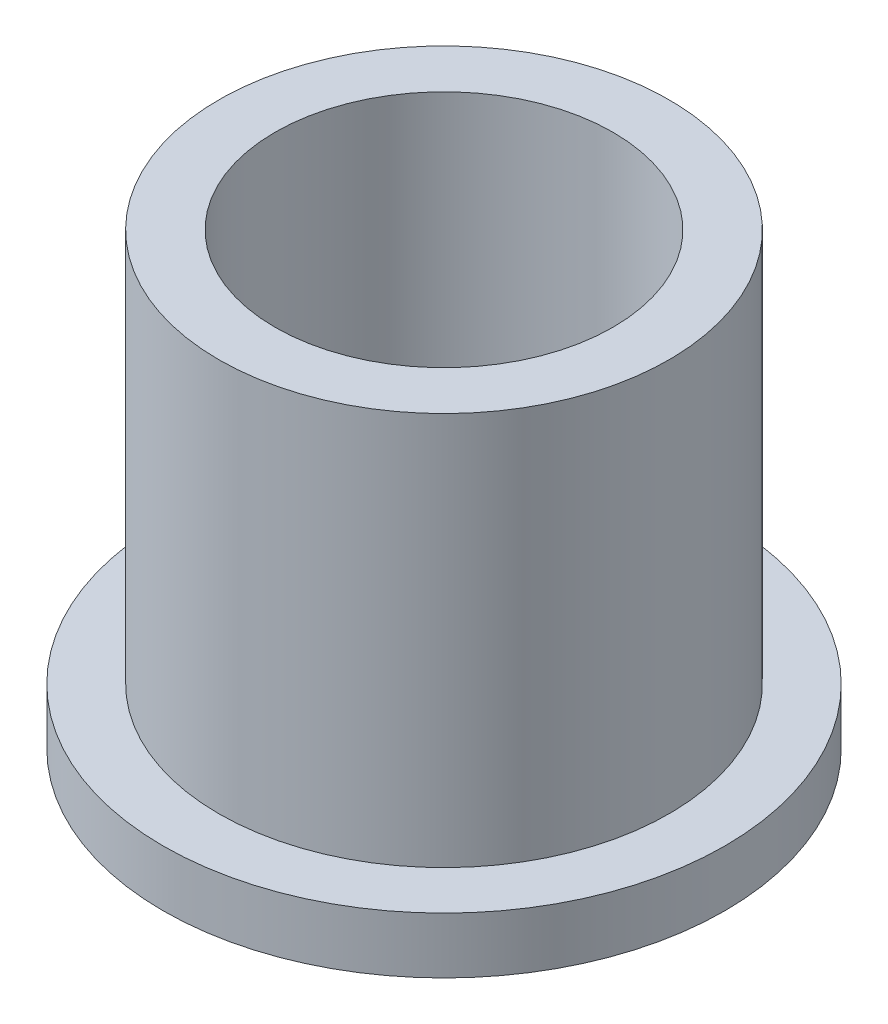
from build123d import *

# Parameters (mm, degrees)
SKETCH2_R           = 6.3627
SKETCH2_R_2         = 4.7752
BOSS_EXTRUDE1_DEPTH = 12.7
SKETCH3_R           = 7.9375
SKETCH3_R_2         = 6.3627
BOSS_EXTRUDE2_DEPTH = 1.5875


with BuildPart() as part:
    # Sketch2 → Boss-Extrude1 (new body)
    with BuildSketch(Plane(origin=(0, 0, 0), x_dir=(1, 0, 0), z_dir=(0, 1, 0))):
        Circle(SKETCH2_R)
        Circle(SKETCH2_R_2, mode=Mode.SUBTRACT)
    extrude(amount=BOSS_EXTRUDE1_DEPTH)

    # Sketch3 → Boss-Extrude2 (add)
    with BuildSketch(Plane(origin=(0, 0, 0), x_dir=(1, 0, 0), z_dir=(0, 1, 0))):
        Circle(SKETCH3_R)
        Circle(SKETCH3_R_2, mode=Mode.SUBTRACT)
    extrude(amount=BOSS_EXTRUDE2_DEPTH)


solid = part.part
